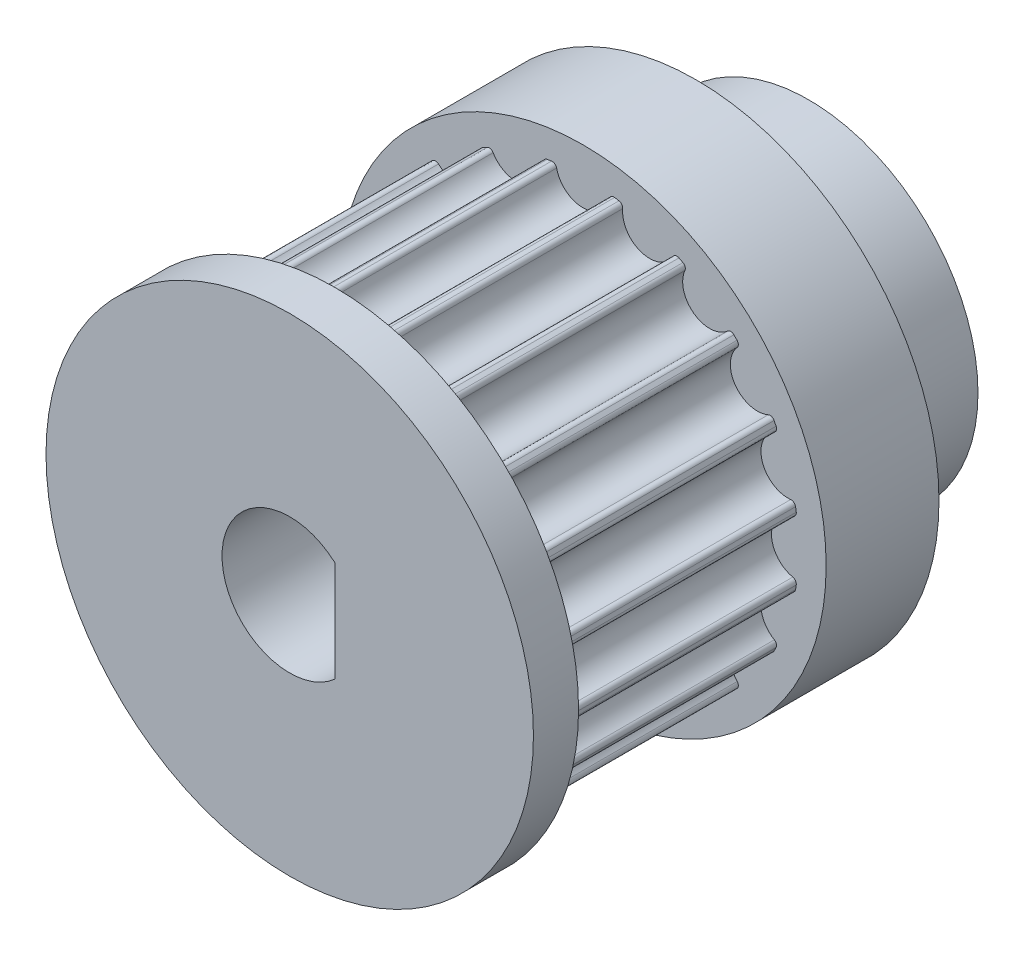
from build123d import *

# Parameters (mm, degrees)
BOSS_EXTRUDE1_DEPTH = 11
FILLET1_R           = 0.2
SKETCH2_R           = 10.8
BOSS_EXTRUDE2_DEPTH = 2
SKETCH3_R           = 10.771373346
BOSS_EXTRUDE3_DEPTH = 10
CUT_EXTRUDE1_DEPTH  = 24
SKETCH6_OUTSIDE_W   = 31.248
SKETCH6_OUTSIDE_H   = 31.248
SKETCH6_OUTSIDE_R   = 7.5
CUT_EXTRUDE2_DEPTH  = 5


with BuildPart() as part:
    # Sketch1 → Boss-Extrude1 (new body)
    with BuildSketch(Plane.XY):
        with BuildLine():
            ThreePointArc((9.474103382, -1.197629054), (8.3495, 0), (9.474103382, 1.197629054))
            ThreePointArc((9.474103382, 1.197629054), (9.431929809, 1.493870924), (9.380495488, 1.788646036))
            ThreePointArc((9.380495488, 1.788646036), (7.940846383, 2.580137395), (8.640320027, 4.066671867))
            ThreePointArc((8.640320027, 4.066671867), (8.508666803, 4.335382277), (8.368659338, 4.59983599))
            ThreePointArc((8.368659338, 4.59983599), (6.754887395, 4.907712964), (6.960761947, 6.537640504))
            ThreePointArc((6.960761947, 6.537640504), (6.752516207, 6.752516207), (6.537640504, 6.960761947))
            ThreePointArc((6.537640504, 6.960761947), (4.907712964, 6.754887395), (4.59983599, 8.368659338))
            ThreePointArc((4.59983599, 8.368659338), (4.335382277, 8.508666803), (4.066671867, 8.640320027))
            ThreePointArc((4.066671867, 8.640320027), (2.580137395, 7.940846383), (1.788646036, 9.380495488))
            ThreePointArc((1.788646036, 9.380495488), (1.493870924, 9.431929809), (1.197629054, 9.474103382))
            ThreePointArc((1.197629054, 9.474103382), (0, 8.3495), (-1.197629054, 9.474103382))
            ThreePointArc((-1.197629054, 9.474103382), (-1.493870924, 9.431929809), (-1.788646036, 9.380495488))
            ThreePointArc((-1.788646036, 9.380495488), (-1.760417133, 9.232490228), (-1.750957788, 9.082114202))
            ThreePointArc((-1.750957788, 9.082114202), (-2.726076592, 7.903374007), (-4.066671867, 8.640320027))
            ThreePointArc((-4.066671867, 8.640320027), (-4.335382277, 8.508666803), (-4.59983599, 8.368659338))
            ThreePointArc((-4.59983599, 8.368659338), (-4.460696136, 8.060474025), (-4.413055267, 7.725707788))
            ThreePointArc((-4.413055267, 7.725707788), (-5.206547139, 6.59665901), (-6.537640504, 6.960761947))
            ThreePointArc((-6.537640504, 6.960761947), (-6.752516207, 6.752516207), (-6.960761947, 6.537640504))
            ThreePointArc((-6.960761947, 6.537640504), (-6.639905087, 6.12396866), (-6.525707788, 5.613055267))
            ThreePointArc((-6.525707788, 5.613055267), (-7.147582309, 4.561498834), (-8.368659338, 4.59983599))
            ThreePointArc((-8.368659338, 4.59983599), (-8.508666803, 4.335382277), (-8.640320027, 4.066671867))
            ThreePointArc((-8.640320027, 4.066671867), (-8.089603998, 3.625437954), (-7.882114202, 2.950957788))
            ThreePointArc((-7.882114202, 2.950957788), (-8.346606739, 2.00278651), (-9.380495488, 1.788646036))
            ThreePointArc((-9.380495488, 1.788646036), (-9.431929809, 1.493870924), (-9.474103382, 1.197629054))
            ThreePointArc((-9.474103382, 1.197629054), (-8.674721188, 0.821438999), (-8.3495, 0))
            ThreePointArc((-8.3495, 0), (-8.674721188, -0.821438999), (-9.474103382, -1.197629054))
            ThreePointArc((-9.474103382, -1.197629054), (-9.431929809, -1.493870924), (-9.380495488, -1.788646036))
            ThreePointArc((-9.380495488, -1.788646036), (-8.346606739, -2.00278651), (-7.882114202, -2.950957788))
            ThreePointArc((-7.882114202, -2.950957788), (-8.089603998, -3.625437954), (-8.640320027, -4.066671867))
            ThreePointArc((-8.640320027, -4.066671867), (-8.508666803, -4.335382277), (-8.368659338, -4.59983599))
            ThreePointArc((-8.368659338, -4.59983599), (-7.147582309, -4.561498834), (-6.525707788, -5.613055267))
            ThreePointArc((-6.525707788, -5.613055267), (-6.639905087, -6.12396866), (-6.960761947, -6.537640504))
            ThreePointArc((-6.960761947, -6.537640504), (-6.752516207, -6.752516207), (-6.537640504, -6.960761947))
            ThreePointArc((-6.537640504, -6.960761947), (-5.206547139, -6.59665901), (-4.413055267, -7.725707788))
            ThreePointArc((-4.413055267, -7.725707788), (-4.460696136, -8.060474025), (-4.59983599, -8.368659338))
            ThreePointArc((-4.59983599, -8.368659338), (-4.335382277, -8.508666803), (-4.066671867, -8.640320027))
            ThreePointArc((-4.066671867, -8.640320027), (-2.726076592, -7.903374007), (-1.750957788, -9.082114202))
            ThreePointArc((-1.750957788, -9.082114202), (-1.760417133, -9.232490228), (-1.788646036, -9.380495488))
            ThreePointArc((-1.788646036, -9.380495488), (-1.493870924, -9.431929809), (-1.197629054, -9.474103382))
            ThreePointArc((-1.197629054, -9.474103382), (0, -8.3495), (1.197629054, -9.474103382))
            ThreePointArc((1.197629054, -9.474103382), (1.493870924, -9.431929809), (1.788646036, -9.380495488))
            ThreePointArc((1.788646036, -9.380495488), (2.580137395, -7.940846383), (4.066671867, -8.640320027))
            ThreePointArc((4.066671867, -8.640320027), (4.335382277, -8.508666803), (4.59983599, -8.368659338))
            ThreePointArc((4.59983599, -8.368659338), (4.907712964, -6.754887395), (6.537640504, -6.960761947))
            ThreePointArc((6.537640504, -6.960761947), (6.752516207, -6.752516207), (6.960761947, -6.537640504))
            ThreePointArc((6.960761947, -6.537640504), (6.754887395, -4.907712964), (8.368659338, -4.59983599))
            ThreePointArc((8.368659338, -4.59983599), (8.508666803, -4.335382277), (8.640320027, -4.066671867))
            ThreePointArc((8.640320027, -4.066671867), (7.940846383, -2.580137395), (9.380495488, -1.788646036))
            ThreePointArc((9.380495488, -1.788646036), (9.431929809, -1.493870924), (9.474103382, -1.197629054))
        make_face()
    extrude(amount=BOSS_EXTRUDE1_DEPTH)

    # Fillet1
    fillet1_edges = [part.edges().sort_by_distance(p)[0] for p in [
        (0, -8.3495, 0),
        (1.197629054, 9.474103382, 5.5),
        (1.788646036, 9.380495488, 5.5),
        (4.066671867, 8.640320027, 5.5),
        (4.59983599, 8.368659338, 5.5),
        (6.537640504, 6.960761947, 5.5),
        (6.960761947, 6.537640504, 5.5),
        (8.368659338, 4.59983599, 5.5),
        (8.640320027, 4.066671867, 5.5),
        (9.380495488, 1.788646036, 5.5),
        (9.474103382, 1.197629054, 5.5),
        (9.474103382, -1.197629054, 5.5),
        (9.380495488, -1.788646036, 5.5),
        (8.640320027, -4.066671867, 5.5),
        (8.368659338, -4.59983599, 5.5),
        (6.960761947, -6.537640504, 5.5),
        (6.537640504, -6.960761947, 5.5),
        (4.59983599, -8.368659338, 5.5),
        (4.066671867, -8.640320027, 5.5),
        (1.788646036, -9.380495488, 5.5),
        (1.197629054, -9.474103382, 5.5),
        (-1.197629054, -9.474103382, 5.5),
        (-1.788646036, -9.380495488, 5.5),
        (-4.066671867, -8.640320027, 5.5),
        (-4.59983599, -8.368659338, 5.5),
        (-6.537640504, -6.960761947, 5.5),
        (-6.960761947, -6.537640504, 5.5),
        (-8.368659338, -4.59983599, 5.5),
        (-8.640320027, -4.066671867, 5.5),
        (-9.380495488, -1.788646036, 5.5),
        (-9.474103382, -1.197629054, 5.5),
        (-9.474103382, 1.197629054, 5.5),
        (-9.380495488, 1.788646036, 5.5),
        (-8.640320027, 4.066671867, 5.5),
        (-8.368659338, 4.59983599, 5.5),
        (-6.960761947, 6.537640504, 5.5),
        (-6.537640504, 6.960761947, 5.5),
        (-4.59983599, 8.368659338, 5.5),
        (-4.066671867, 8.640320027, 5.5),
        (-1.788646036, 9.380495488, 5.5),
        (-1.197629054, 9.474103382, 5.5),
    ]]
    fillet(fillet1_edges, radius=FILLET1_R)

    # Sketch2 → Boss-Extrude2 (add)
    with BuildSketch(Plane.XY.offset(11)):
        Circle(SKETCH2_R)
    extrude(amount=BOSS_EXTRUDE2_DEPTH)

    # Sketch3 → Boss-Extrude3 (add)
    with BuildSketch(Plane(origin=(0, 0, 0), x_dir=(-1, 0, 0), z_dir=(0, 0, -1))):
        Circle(SKETCH3_R)
    extrude(amount=BOSS_EXTRUDE3_DEPTH)

    # Sketch5 → Cut-Extrude1 (cut, through all)
    with BuildSketch(Plane.XY.offset(13)):
        with BuildLine():
            Line((2, -2.236067977), (2, 2.236067977))
            ThreePointArc((2, 2.236067977), (-3, 0), (2, -2.236067977))
        make_face()
    extrude(amount=-CUT_EXTRUDE1_DEPTH, mode=Mode.SUBTRACT)

    # Sketch6 outside → Cut-Extrude2 (cut)
    with BuildSketch(Plane(origin=(0, 0, -10), x_dir=(-1, 0, 0), z_dir=(0, 0, -1))):
        Rectangle(SKETCH6_OUTSIDE_W, SKETCH6_OUTSIDE_H)
        Circle(SKETCH6_OUTSIDE_R, mode=Mode.SUBTRACT)
    extrude(amount=-CUT_EXTRUDE2_DEPTH, mode=Mode.SUBTRACT)


solid = part.part
